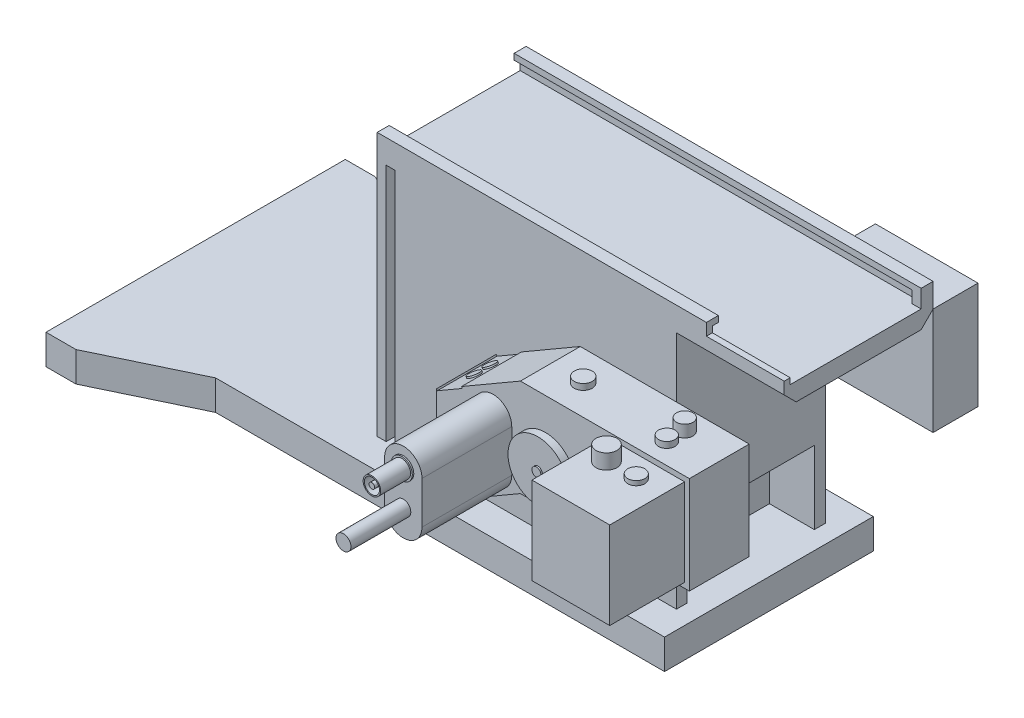
from build123d import *

# Parameters (mm, degrees)
BOSS_EXTRUDE1_DEPTH      = 10
BOSS_EXTRUDE3_DEPTH      = 80
SKETCH4_W                = 42.48647226
SKETCH4_H                = 24.378381935
CUT_EXTRUDE2_DEPTH       = 15
SKETCH5_W                = 70
SKETCH5_H                = 43.763948065
CUT_EXTRUDE3_DEPTH       = 80
BOSS_EXTRUDE4_DEPTH      = 10
BOSS_EXTRUDE4_DEPTH_BACK = 100
SKETCH6_R                = 30
CUT_EXTRUDE5_DEPTH       = 46
SKETCH8_W                = 41.763948065
SKETCH8_H                = 2
BOSS_EXTRUDE5_DEPTH      = 26
BOSS_EXTRUDE5_DEPTH_BACK = 110
SKETCH9_W                = 41.763948065
SKETCH9_H                = 4
BOSS_EXTRUDE6_DEPTH      = 26
BOSS_EXTRUDE6_DEPTH_BACK = 10
BOSS_EXTRUDE7_DEPTH      = 26
BOSS_EXTRUDE7_DEPTH_BACK = 10
BOSS_EXTRUDE8_DEPTH      = 26
BOSS_EXTRUDE9_DEPTH      = 26
SKETCH13_W               = 2
SKETCH13_H               = 4
BOSS_EXTRUDE10_DEPTH     = 3
SKETCH14_W               = 34.278285875
SKETCH14_H               = 35.763672782
BOSS_EXTRUDE11_DEPTH     = 15
BOSS_EXTRUDE12_DEPTH     = 20
SKETCH16_W               = 26.010260239
SKETCH16_H               = 29.112401369
BOSS_EXTRUDE13_DEPTH     = 25
SKETCH17_R               = 3.5
BOSS_EXTRUDE14_DEPTH     = 5
SKETCH18_R               = 2.846394249
BOSS_EXTRUDE15_DEPTH     = 1.5
SKETCH19_R               = 3
BOSS_EXTRUDE16_DEPTH     = 2
SKETCH20_R               = 2.75
BOSS_EXTRUDE17_DEPTH     = 2
SKETCH21_R               = 2.75
BOSS_EXTRUDE18_DEPTH     = 2
SKETCH22_R               = 1
BOSS_EXTRUDE19_DEPTH     = 5
SKETCH23_R               = 10
BOSS_EXTRUDE20_DEPTH     = 3
SKETCH24_R               = 10
SKETCH24_R_2             = 1.5
CUT_EXTRUDE6_DEPTH       = 0.5
SKETCH25_W               = 9.698325035
SKETCH25_H               = 20
CUT_EXTRUDE7_DEPTH       = 0.5
BOSS_EXTRUDE21_DEPTH     = 30
SKETCH27_R               = 2
BOSS_EXTRUDE22_DEPTH     = 0.5
SKETCH29_R               = 3.5
BOSS_EXTRUDE23_DEPTH     = 0.5
SKETCH30_R               = 2.924767118
SKETCH30_R_2             = 2.520102258
SKETCH30_R_3             = 0.938230535
BOSS_EXTRUDE24_DEPTH     = 10
SKETCH31_R               = 2.5
BOSS_EXTRUDE25_DEPTH     = 20
SKETCH32_R               = 33.10203112
BOSS_EXTRUDE26_DEPTH     = 1
BOSS_EXTRUDE26_TAPER     = 20


with BuildPart() as part:
    # Sketch1 → Boss-Extrude1 (new body)
    with BuildSketch(Plane(origin=(0, 0, 0), x_dir=(1, 0, 0), z_dir=(0, 1, 0))):
        Polygon((0, 0), (0, 100), (10, 100), (41.566521678, 84.881974033), (191.566521678, 84.881974033), (191.566521678, 15.118025967), (41.566521678, 15.118025967), (10, 0), align=None)
    extrude(amount=BOSS_EXTRUDE1_DEPTH)

    # Sketch3 → Boss-Extrude3 (add)
    with BuildSketch(Plane(origin=(0, 10, 0), x_dir=(1, 0, 0), z_dir=(0, 1, 0))):
        Polygon((91.501482994, 28.169402175), (91.501482994, 25.17192825), (185.501482994, 25.17192825), (185.501482994, 74.935876315), (91.501482994, 74.935876315), (91.501482994, 71.93840239), (88.501482994, 71.93840239), (88.501482994, 74.935876315), (85.501482994, 74.935876315), (85.501482994, 25.17192825), (88.501482994, 25.17192825), (88.501482994, 28.169402175), align=None)
    extrude(amount=BOSS_EXTRUDE3_DEPTH)

    # Sketch4 → Cut-Extrude2 (cut)
    with BuildSketch(Plane(origin=(185.501482994, 0, 0), x_dir=(0, 0, -1), z_dir=(1, 0, 0))):
        with Locations((50, 22.189190968)):
            Rectangle(SKETCH4_W, SKETCH4_H)
    extrude(amount=-CUT_EXTRUDE2_DEPTH, mode=Mode.SUBTRACT)

    # Sketch5 → Cut-Extrude3 (cut)
    with BuildSketch(Plane(origin=(0, 90, 0), x_dir=(1, 0, 0), z_dir=(0, 1, 0))):
        with Locations((131.501482994, 50.053902283)):
            Rectangle(SKETCH5_W, SKETCH5_H)
    extrude(amount=-CUT_EXTRUDE3_DEPTH, mode=Mode.SUBTRACT)

    # Sketch7 → Boss-Extrude4 (add, two sides)
    with BuildSketch(Plane(origin=(185.501482994, 0, 0), x_dir=(0, 0, -1), z_dir=(1, 0, 0))) as boss_extrude4_sk:
        Polygon((25.17192825, 98), (25.17192825, 90), (29.17192825, 90), (29.17192825, 92), (27.17192825, 92), (27.17192825, 96), (29.17192825, 96), (29.17192825, 98), align=None)
        Polygon((70.935876315, 92), (70.935876315, 90), (74.935876315, 90), (74.935876315, 98), (70.935876315, 98), (70.935876315, 96), (72.935876315, 96), (72.935876315, 92), align=None)
    extrude(amount=BOSS_EXTRUDE4_DEPTH)
    extrude(boss_extrude4_sk.sketch, amount=-BOSS_EXTRUDE4_DEPTH_BACK)

    # Sketch6 → Cut-Extrude5 (cut)
    with BuildSketch(Plane(origin=(0, 0, -74.935876315), x_dir=(-1, 0, 0), z_dir=(0, 0, -1))):
        with Locations((-130.873377136, 50)):
            Circle(SKETCH6_R)
    extrude(amount=-CUT_EXTRUDE5_DEPTH, mode=Mode.SUBTRACT)

    # Sketch8 → Boss-Extrude5 (add, two sides)
    with BuildSketch(Plane(origin=(195.501482994, 0, 0), x_dir=(0, 0, -1), z_dir=(1, 0, 0))) as boss_extrude5_sk:
        with Locations((50.053902283, 91)):
            Rectangle(SKETCH8_W, SKETCH8_H)
    extrude(amount=BOSS_EXTRUDE5_DEPTH)
    extrude(boss_extrude5_sk.sketch, amount=-BOSS_EXTRUDE5_DEPTH_BACK)

    # Sketch9 → Boss-Extrude6 (add, two sides)
    with BuildSketch(Plane(origin=(195.501482994, 0, 0), x_dir=(0, 0, -1), z_dir=(1, 0, 0))) as boss_extrude6_sk:
        with Locations((50.053902283, 88)):
            Rectangle(SKETCH9_W, SKETCH9_H)
    extrude(amount=BOSS_EXTRUDE6_DEPTH)
    extrude(boss_extrude6_sk.sketch, amount=-BOSS_EXTRUDE6_DEPTH_BACK)

    # Sketch10 → Boss-Extrude7 (add, two sides)
    with BuildSketch(Plane(origin=(195.501482994, 0, 0), x_dir=(0, 0, -1), z_dir=(1, 0, 0))) as boss_extrude7_sk:
        Polygon((25.17192825, 90), (29.17192825, 86), (29.17192825, 90), align=None)
        Polygon((74.935876315, 90), (70.935876315, 90), (70.935876315, 86), align=None)
    extrude(amount=BOSS_EXTRUDE7_DEPTH)
    extrude(boss_extrude7_sk.sketch, amount=-BOSS_EXTRUDE7_DEPTH_BACK)

    # Sketch11 → Boss-Extrude8 (add)
    with BuildSketch(Plane(origin=(195.501482994, 0, 0), x_dir=(0, 0, -1), z_dir=(1, 0, 0))):
        Polygon((70.935876315, 98), (74.935876315, 98), (74.935876315, 90), (70.935876315, 90), (70.935876315, 92), (72.935876315, 92), (72.935876315, 96), (70.935876315, 96), align=None)
    extrude(amount=BOSS_EXTRUDE8_DEPTH)

    # Sketch12 → Boss-Extrude9 (add)
    with BuildSketch(Plane(origin=(195.501482994, 0, 0), x_dir=(0, 0, -1), z_dir=(1, 0, 0))):
        Polygon((25.17192825, 90), (29.17192825, 90), (29.17192825, 92), (27.17192825, 92), (27.17192825, 94), (25.17192825, 94), align=None)
    extrude(amount=BOSS_EXTRUDE9_DEPTH)

    # Sketch13 → Boss-Extrude10 (add)
    with BuildSketch(Plane(origin=(221.501482994, 0, 0), x_dir=(0, 0, -1), z_dir=(1, 0, 0))):
        with Locations((71.935876315, 94)):
            Rectangle(SKETCH13_W, SKETCH13_H)
    extrude(amount=-BOSS_EXTRUDE10_DEPTH)

    # Sketch15 → Boss-Extrude12 (add)
    with BuildSketch(Plane.XY.offset(-25.17192825)):
        Polygon((153.35639721, 69.956434263), (125.299022411, 53.676229133), (125.299022411, 21.116229133), (153.35639721, 37.396024003), (209.817534152, 37.396024003), (209.817534152, 69.956434263), align=None)
    extrude(amount=BOSS_EXTRUDE12_DEPTH)

    # Sketch16 → Boss-Extrude13 (add)
    with BuildSketch(Plane.XY.offset(-5.17192825)):
        with Locations((195.204870599, 53.680511347)):
            Rectangle(SKETCH16_W, SKETCH16_H)
    extrude(amount=BOSS_EXTRUDE13_DEPTH)

    # Sketch17 → Boss-Extrude14 (add)
    with BuildSketch(Plane(origin=(0, 68.236712031, 0), x_dir=(1, 0, 0), z_dir=(0, 1, 0))):
        with Locations(Location((189.337705988, -2.050762932, 0), (0, 0, 90))):
            Circle(SKETCH17_R)
    extrude(amount=BOSS_EXTRUDE14_DEPTH)

    # Sketch18 → Boss-Extrude15 (add)
    with BuildSketch(Plane(origin=(0, 68.236712031, 0), x_dir=(1, 0, 0), z_dir=(0, 1, 0))):
        with Locations(Location((199.293404671, -2.050762932, 0), (0, 0, 90))):
            Circle(SKETCH18_R)
    extrude(amount=BOSS_EXTRUDE15_DEPTH)

    # Sketch19 → Boss-Extrude16 (add)
    with BuildSketch(Plane(origin=(0, 69.956434263, 0), x_dir=(1, 0, 0), z_dir=(0, 1, 0))):
        with Locations(Location((164.447971489, 15.072442256, 0), (0, 0, 90))):
            Circle(SKETCH19_R)
    extrude(amount=BOSS_EXTRUDE16_DEPTH)

    # Sketch20 → Boss-Extrude17 (add)
    with BuildSketch(Plane(origin=(0, 69.956434263, 0), x_dir=(1, 0, 0), z_dir=(0, 1, 0))):
        with Locations(Location((195.365674229, 18.072442256, 0), (0, 0, 90))):
            Circle(SKETCH20_R)
        with Locations(Location((195.365674229, 12.072442256, 0), (0, 0, 90))):
            Circle(SKETCH20_R)
    extrude(amount=BOSS_EXTRUDE17_DEPTH)

    # Sketch21 → Boss-Extrude18 (add)
    with BuildSketch(Plane(origin=(0, 71.956434263, 0), x_dir=(1, 0, 0), z_dir=(0, 1, 0))):
        with Locations(Location((195.365674229, 18.072442256, 0), (0, 0, 90))):
            Circle(SKETCH21_R)
    extrude(amount=BOSS_EXTRUDE18_DEPTH)

    # Sketch22 → Boss-Extrude19 (add)
    with BuildSketch(Plane.XY.offset(-5.17192825)):
        with Locations(Location((166.695562799, 54.276945118, 0), (0, 0, 180))):
            Circle(SKETCH22_R)
    extrude(amount=BOSS_EXTRUDE19_DEPTH)

    # Sketch23 → Boss-Extrude20 (add)
    with BuildSketch(Plane.XY.offset(-0.17192825)):
        with Locations((166.695562799, 54.276945118)):
            Circle(SKETCH23_R)
    extrude(amount=BOSS_EXTRUDE20_DEPTH)

    # Sketch24 → Cut-Extrude6 (cut)
    with BuildSketch(Plane.XY.offset(2.82807175)):
        with Locations((166.695562799, 54.276945118)):
            Circle(SKETCH24_R)
        with Locations((166.695562799, 54.276945118)):
            Circle(SKETCH24_R_2, mode=Mode.SUBTRACT)
    extrude(amount=-CUT_EXTRUDE6_DEPTH, mode=Mode.SUBTRACT)

    # Sketch25 → Cut-Extrude7 (cut)
    with BuildSketch(Plane(origin=(8.259992725, -14.235306611, 0), x_dir=(0.864938486881547, 0.5018778874497861, 0), z_dir=(-0.5018778874497861, 0.864938486881547, 0))):
        with Locations((140.164021854, 15.17192825)):
            Rectangle(SKETCH25_W, SKETCH25_H)
    extrude(amount=-CUT_EXTRUDE7_DEPTH, mode=Mode.SUBTRACT)

    # Sketch26 → Boss-Extrude21 (add)
    with BuildSketch(Plane.XY.offset(-5.17192825)):
        with BuildLine():
            Line((150.464109956, 55.324272259), (150.464109956, 41.214184102))
            ThreePointArc((150.464109956, 41.214184102), (144.227874784, 34.97794893), (137.991639612, 41.214184102))
            Line((137.991639612, 41.214184102), (137.991639612, 55.324272259))
            ThreePointArc((137.991639612, 55.324272259), (144.227874784, 61.560507431), (150.464109956, 55.324272259))
        make_face()
    extrude(amount=BOSS_EXTRUDE21_DEPTH)

    # Sketch27 → Boss-Extrude22 (add)
    with BuildSketch(Plane(origin=(8.510931669, -14.667775854, 0), x_dir=(0.8649384868815474, 0.5018778874497855, 0), z_dir=(-0.5018778874497855, 0.8649384868815474, 0))):
        with Locations((140.0542313, 18.876498652)):
            Circle(SKETCH27_R)
        with Locations((140.0542313, 13.553842308)):
            Circle(SKETCH27_R)
    extrude(amount=BOSS_EXTRUDE22_DEPTH)

    # Sketch29 → Boss-Extrude23 (add)
    with BuildSketch(Plane.XY.offset(24.82807175)):
        with Locations((144.227874784, 55.324272259)):
            Circle(SKETCH29_R)
    extrude(amount=BOSS_EXTRUDE23_DEPTH)

    # Sketch30 → Boss-Extrude24 (add)
    with BuildSketch(Plane.XY.offset(25.32807175)):
        with Locations((144.227874784, 55.324272259)):
            Circle(SKETCH30_R)
        with Locations((144.227874784, 55.324272259)):
            Circle(SKETCH30_R_2, mode=Mode.SUBTRACT)
        with Locations((144.227874784, 55.324272259)):
            Circle(SKETCH30_R_3)
    extrude(amount=BOSS_EXTRUDE24_DEPTH)

    # Sketch31 → Boss-Extrude25 (add)
    with BuildSketch(Plane.XY.offset(24.82807175)):
        with Locations((144.227874784, 43.715821473)):
            Circle(SKETCH31_R)
    extrude(amount=BOSS_EXTRUDE25_DEPTH)


with BuildPart() as body_2:
    # Sketch14 → Boss-Extrude11 (new body)
    with BuildSketch(Plane(origin=(0, 0, -74.935876315), x_dir=(-1, 0, 0), z_dir=(0, 0, -1))):
        with Locations((-204.362340057, 72.118163609)):
            Rectangle(SKETCH14_W, SKETCH14_H)
    extrude(amount=BOSS_EXTRUDE11_DEPTH)


with BuildPart() as body_3:
    # Sketch32 → Boss-Extrude26 (new body)
    with BuildSketch(Plane(origin=(0, 0, -74.935876315), x_dir=(-1, 0, 0), z_dir=(0, 0, -1))):
        with Locations((-130.873377136, 50)):
            Circle(SKETCH32_R)
    extrude(amount=BOSS_EXTRUDE26_DEPTH, taper=BOSS_EXTRUDE26_TAPER)


solid = Compound([part.part, body_2.part, body_3.part])
